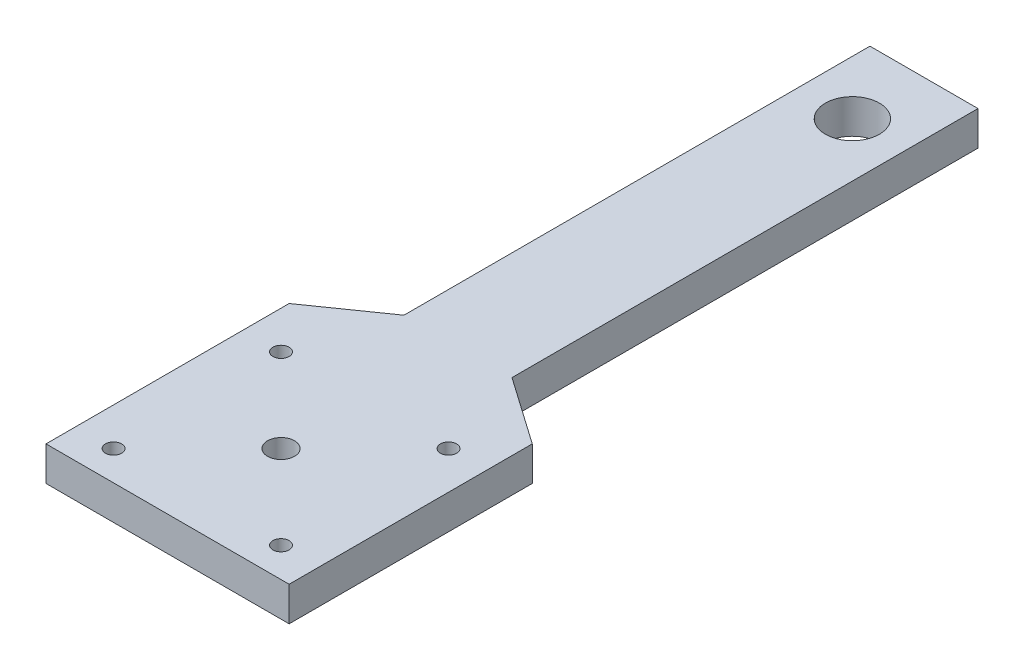
from build123d import *

# Parameters (mm, degrees)
SKETCH1_R           = 5
SKETCH1_R_2         = 1.5
SKETCH1_R_3         = 2.5
BOSS_EXTRUDE1_DEPTH = 6.35


with BuildPart() as part:
    # Sketch1 → Boss-Extrude1 (new body)
    with BuildSketch(Plane(origin=(0, 0, 0), x_dir=(1, 0, 0), z_dir=(0, 1, 0))):
        Polygon((-10, -9.622405772), (-10, 76.625), (10, 76.625), (10, -9.622405772), (22.5, -18.375), (22.5, -63.375), (0, -63.375), (-22.5, -63.375), (-22.5, -18.375), align=None)
        with Locations((0, 63.375)):
            Circle(SKETCH1_R, mode=Mode.SUBTRACT)
        with Locations((-15.5, -26.875)):
            Circle(SKETCH1_R_2, mode=Mode.SUBTRACT)
        with Locations((15.5, -26.875)):
            Circle(SKETCH1_R_2, mode=Mode.SUBTRACT)
        with Locations((15.5, -57.875)):
            Circle(SKETCH1_R_2, mode=Mode.SUBTRACT)
        with Locations((-15.5, -57.875)):
            Circle(SKETCH1_R_2, mode=Mode.SUBTRACT)
        with Locations((0, -42.375)):
            Circle(SKETCH1_R_3, mode=Mode.SUBTRACT)
    extrude(amount=BOSS_EXTRUDE1_DEPTH)


solid = part.part
